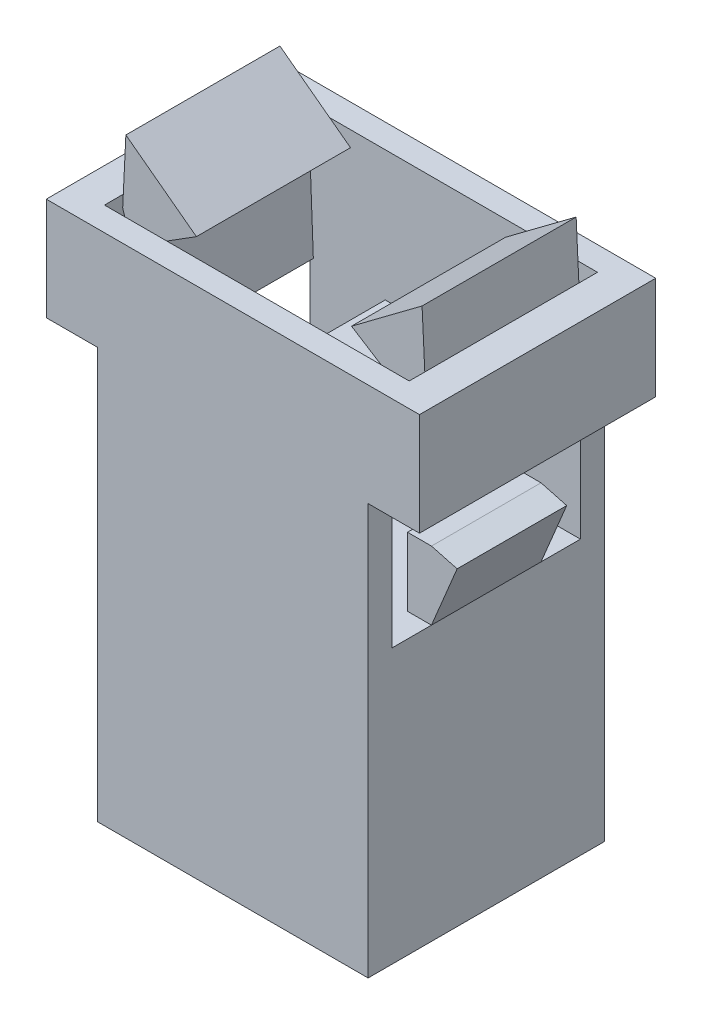
from build123d import *

# Parameters (mm, degrees)
SKETCH1_W                       = 7.9
SKETCH1_H                       = 6.9
BOSS_EXTRUDE1_DEPTH             = 12
SKETCH2_W                       = 10.9
SKETCH2_H                       = 6.9
BOSS_EXTRUDE2_DEPTH             = 3
SKETCH3_W                       = 8.9
SKETCH3_H                       = 5.5
CUT_EXTRUDE1_DEPTH              = 7
SKETCH4_W                       = 0.7
SKETCH4_H                       = 2
BOSS_EXTRUDE3_DEPTH             = 1.6
BOSS_EXTRUDE3_DEPTH_BACK        = 1.6
BOSS_EXTRUDE4_DEPTH             = 2.25
BOSS_EXTRUDE4_DEPTH_BACK        = 2.25
BOSS_EXTRUDE5_REACH             = 18.328
BOSS_EXTRUDE5_DIRECTION_2_REACH = 18.328


with BuildPart() as part:
    # Sketch1 → Boss-Extrude1 (new body)
    with BuildSketch(Plane(origin=(0, 0, 0), x_dir=(1, 0, 0), z_dir=(0, 1, 0))):
        Rectangle(SKETCH1_W, SKETCH1_H)
    extrude(amount=BOSS_EXTRUDE1_DEPTH)

    # Sketch2 → Boss-Extrude2 (add)
    with BuildSketch(Plane(origin=(0, 12, 0), x_dir=(1, 0, 0), z_dir=(0, 1, 0))):
        Rectangle(SKETCH2_W, SKETCH2_H)
    extrude(amount=BOSS_EXTRUDE2_DEPTH)

    # Sketch3 → Cut-Extrude1 (cut)
    with BuildSketch(Plane(origin=(0, 15, 0), x_dir=(1, 0, 0), z_dir=(0, 1, 0))):
        Rectangle(SKETCH3_W, SKETCH3_H)
    extrude(amount=-CUT_EXTRUDE1_DEPTH, mode=Mode.SUBTRACT)

    # Sketch4 → Boss-Extrude3 (add, two sides)
    with BuildSketch(Plane.XY) as boss_extrude3_sk:
        Polygon((-3.95, 10), (-3.95, 8), (-4.7, 9.8), align=None)
        with Locations((-3.6, 9)):
            Rectangle(SKETCH4_W, SKETCH4_H)
    boss_extrude3 = extrude(amount=BOSS_EXTRUDE3_DEPTH)
    boss_extrude3 = boss_extrude3 + extrude(boss_extrude3_sk.sketch, amount=-BOSS_EXTRUDE3_DEPTH_BACK)

    # Mirror1: Boss-Extrude3 across plane
    add(boss_extrude3.mirror(Plane(origin=(0, 0, 0), x_dir=(0, 0, 1), z_dir=(1, 0, 0))))


with BuildPart() as body_2:
    # Sketch5 → Boss-Extrude4 (new, two sides)
    with BuildSketch(Plane.XY) as boss_extrude4_sk:
        Polygon((-1.25, 11.7), (1.25, 11.7), (2.45, 9.95), (-2.45, 9.95), align=None)
    extrude(amount=BOSS_EXTRUDE4_DEPTH)
    extrude(boss_extrude4_sk.sketch, amount=-BOSS_EXTRUDE4_DEPTH_BACK)


with BuildPart() as body_3:

    # Boss-Extrude5: up to this face of the body (flat: up to its plane)
    boss_extrude5_end = Plane(body_2.part.faces().sort_by_distance((0, 10.730405405, 2.25))[0])
    # Sketch6 → Boss-Extrude5 (new, up to the picked face)
    with BuildSketch(Plane.XY, mode=Mode.PRIVATE) as boss_extrude5_sk1:
        Polygon((3.471778858, 11.63828639), (3.35, 11.7), (3.449808304, 14.298083583), (2.265137871, 15.044110369), (4.325591119, 16.585526334), (4.418044618, 14.695177149), align=None)
    boss_extrude5_tool1 = split(extrude(boss_extrude5_sk1.sketch, amount=BOSS_EXTRUDE5_REACH, mode=Mode.PRIVATE), bisect_by=boss_extrude5_end, keep=Keep.BOTH, mode=Mode.PRIVATE)
    # Sketch6 → Boss-Extrude5 (new, up to the picked face)
    with BuildSketch(Plane.XY, mode=Mode.PRIVATE) as boss_extrude5_sk2:
        Polygon((-4.325591119, 16.585526334), (-2.265137871, 15.044110369), (-3.449808304, 14.298083583), (-3.35, 11.7), (-3.471778858, 11.63828639), (-4.418044618, 14.695177149), align=None)
    boss_extrude5_tool2 = split(extrude(boss_extrude5_sk2.sketch, amount=BOSS_EXTRUDE5_REACH, mode=Mode.PRIVATE), bisect_by=boss_extrude5_end, keep=Keep.BOTH, mode=Mode.PRIVATE)
    add(boss_extrude5_tool1.solids().sort_by(Axis((3.652081, 14.612353, 0), (0, 0, 1)))[0])
    add(boss_extrude5_tool2.solids().sort_by(Axis((-3.652081, 14.612353, 0), (0, 0, 1)))[0])


    # Boss-Extrude5 direction 2: up to this face of the body (flat: up to its plane)
    boss_extrude5_direction_2_end = Plane(body_2.part.faces().sort_by_distance((0, 10.730405405, -2.25))[0])
    # Sketch6 → Boss-Extrude5 direction 2 (add, up to the picked face)
    with BuildSketch(Plane.XY, mode=Mode.PRIVATE) as boss_extrude5_direction_2_sk1:
        Polygon((3.471778858, 11.63828639), (3.35, 11.7), (3.449808304, 14.298083583), (2.265137871, 15.044110369), (4.325591119, 16.585526334), (4.418044618, 14.695177149), align=None)
    boss_extrude5_direction_2_tool1 = split(extrude(boss_extrude5_direction_2_sk1.sketch, amount=-BOSS_EXTRUDE5_DIRECTION_2_REACH, mode=Mode.PRIVATE), bisect_by=boss_extrude5_direction_2_end, keep=Keep.BOTH, mode=Mode.PRIVATE)
    # Sketch6 → Boss-Extrude5 direction 2 (add, up to the picked face)
    with BuildSketch(Plane.XY, mode=Mode.PRIVATE) as boss_extrude5_direction_2_sk2:
        Polygon((-4.325591119, 16.585526334), (-2.265137871, 15.044110369), (-3.449808304, 14.298083583), (-3.35, 11.7), (-3.471778858, 11.63828639), (-4.418044618, 14.695177149), align=None)
    boss_extrude5_direction_2_tool2 = split(extrude(boss_extrude5_direction_2_sk2.sketch, amount=-BOSS_EXTRUDE5_DIRECTION_2_REACH, mode=Mode.PRIVATE), bisect_by=boss_extrude5_direction_2_end, keep=Keep.BOTH, mode=Mode.PRIVATE)
    add(boss_extrude5_direction_2_tool1.solids().sort_by(Axis((3.652081, 14.612353, 0), (0, 0, -1)))[0])
    add(boss_extrude5_direction_2_tool2.solids().sort_by(Axis((-3.652081, 14.612353, 0), (0, 0, -1)))[0])


solid = Compound([part.part, body_2.part, body_3.part])
